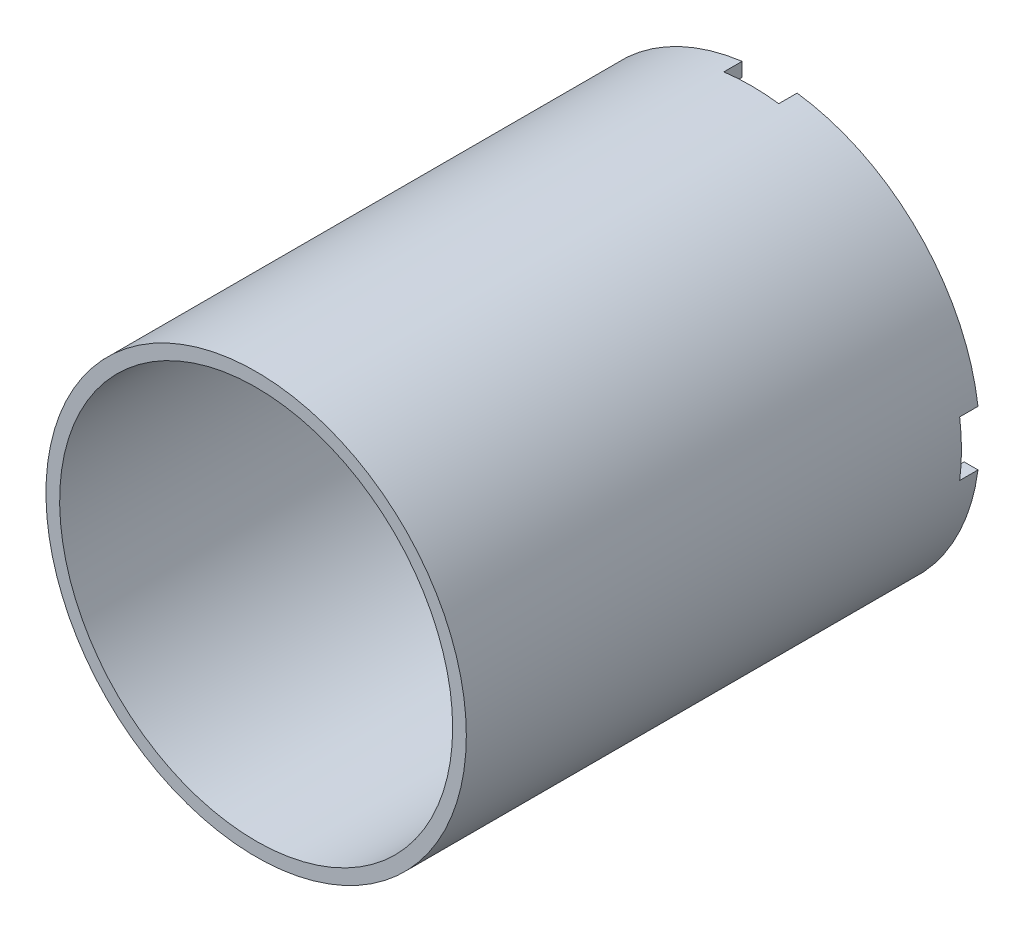
from build123d import *

# Parameters (mm, degrees)
SKETCH1_R           = 45.847
SKETCH1_R_2         = 42.8625
BOSS_EXTRUDE1_DEPTH = 112
CUT_EXTRUDE1_DEPTH  = 4


with BuildPart() as part:
    # Sketch1 → Boss-Extrude1 (new body)
    with BuildSketch(Plane.XY):
        Circle(SKETCH1_R)
        Circle(SKETCH1_R_2, mode=Mode.SUBTRACT)
    extrude(amount=BOSS_EXTRUDE1_DEPTH)

    # Sketch3 → Cut-Extrude1 (cut)
    with BuildSketch(Plane(origin=(0, 0, 0), x_dir=(-1, 0, 0), z_dir=(0, 0, -1))):
        Polygon((6, 45.847), (-6, 45.847), (-6, 6), (-45.847, 6), (-45.847, -6), (-6, -6), (-6, -45.847), (6, -45.847), (6, -6), (45.847, -6), (45.847, 6), (6, 6), align=None)
    extrude(amount=-CUT_EXTRUDE1_DEPTH, mode=Mode.SUBTRACT)


solid = part.part
